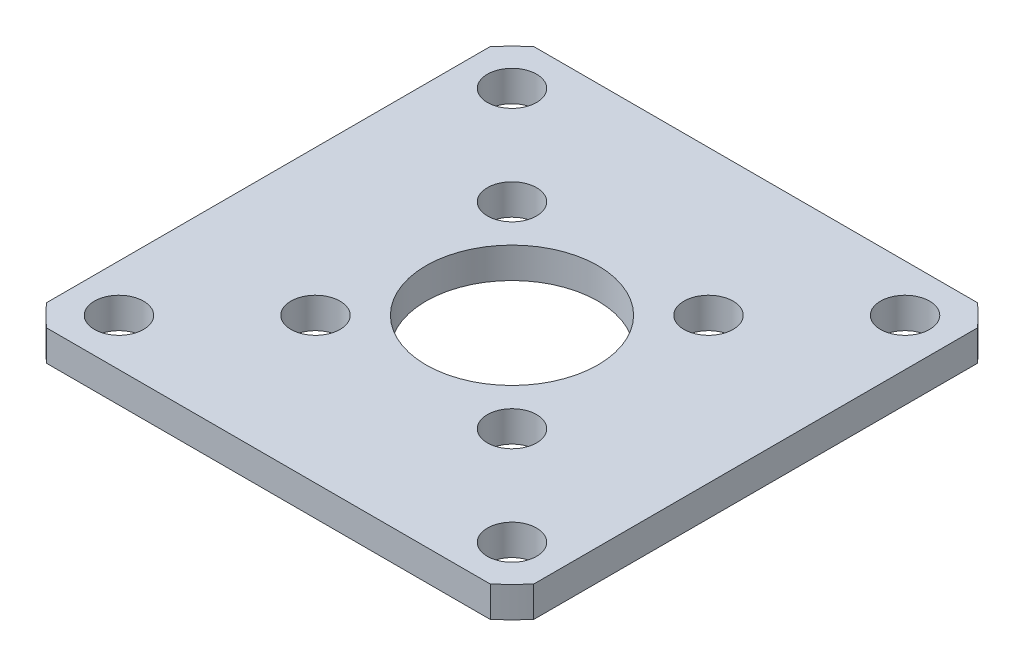
from build123d import *

# Parameters (mm, degrees)
SKETCH1_R           = 26.83
SKETCH1_R_2         = 7
SKETCH1_R_3         = 2
BOSS_EXTRUDE1_DEPTH = 2.5
CUT_EXTRUDE1_DEPTH  = 10
CUT_EXTRUDE2_DEPTH  = 10


with BuildPart() as part:
    # Sketch1 → Boss-Extrude1 (new body)
    with BuildSketch(Plane(origin=(0, 0, 0), x_dir=(1, 0, 0), z_dir=(0, 1, 0))):
        Circle(SKETCH1_R)
        Circle(SKETCH1_R_2, mode=Mode.SUBTRACT)
        with Locations((-16.000000001, 16.000000001)):
            Circle(SKETCH1_R_3, mode=Mode.SUBTRACT)
        with Locations((16.000000001, 16.000000001)):
            Circle(SKETCH1_R_3, mode=Mode.SUBTRACT)
        with Locations((16.000000001, -16.000000001)):
            Circle(SKETCH1_R_3, mode=Mode.SUBTRACT)
        with Locations((-16.000000001, -16.000000001)):
            Circle(SKETCH1_R_3, mode=Mode.SUBTRACT)
    extrude(amount=BOSS_EXTRUDE1_DEPTH)

    # Sketch2 → Cut-Extrude1 (cut)
    with BuildSketch(Plane(origin=(0, 2.5, 0), x_dir=(1, 0, 0), z_dir=(0, 1, 0))):
        with BuildLine():
            ThreePointArc((-6.000000001, 8.000000001), (-9.414213563, 9.414213563), (-8.000000001, 6.000000001))
            Line((-8.000000001, 6.000000001), (-8.000000001, 8.000000001))
            Line((-8.000000001, 8.000000001), (-6.000000001, 8.000000001))
        make_face()
        with BuildLine():
            Line((-8.000000001, 8.000000001), (-8.000000001, 6.000000001))
            ThreePointArc((-8.000000001, 6.000000001), (-6.585786438, 6.585786438), (-6.000000001, 8.000000001))
            Line((-6.000000001, 8.000000001), (-8.000000001, 8.000000001))
        make_face()
        with BuildLine():
            ThreePointArc((6.000000001, 8.000000001), (6.585786438, 6.585786438), (8.000000001, 6.000000001))
            Line((8.000000001, 6.000000001), (8.000000001, 8.000000001))
            Line((8.000000001, 8.000000001), (6.000000001, 8.000000001))
        make_face()
        with BuildLine():
            Line((8.000000001, 8.000000001), (8.000000001, 6.000000001))
            ThreePointArc((8.000000001, 6.000000001), (9.414213563, 6.585786438), (10.000000001, 8.000000001))
            ThreePointArc((10.000000001, 8.000000001), (8.000000001, 10.000000001), (6.000000001, 8.000000001))
            Line((6.000000001, 8.000000001), (8.000000001, 8.000000001))
        make_face()
        with BuildLine():
            Line((-6.000000001, -8.000000001), (-8.000000001, -8.000000001))
            Line((-8.000000001, -8.000000001), (-8.000000001, -6.000000001))
            ThreePointArc((-8.000000001, -6.000000001), (-9.414213563, -9.414213563), (-6.000000001, -8.000000001))
        make_face()
        with BuildLine():
            ThreePointArc((-6.000000001, -8.000000001), (-6.152240936, -7.234633136), (-6.585786438, -6.585786438))
            Line((-6.585786438, -6.585786438), (-8.000000001, -8.000000001))
            Line((-8.000000001, -8.000000001), (-6.000000001, -8.000000001))
        make_face()
        with BuildLine():
            Line((-8.000000001, -8.000000001), (-6.585786438, -6.585786438))
            ThreePointArc((-6.585786438, -6.585786438), (-7.234633136, -6.152240936), (-8.000000001, -6.000000001))
            Line((-8.000000001, -6.000000001), (-8.000000001, -8.000000001))
        make_face()
        with BuildLine():
            ThreePointArc((8.000000001, -6.000000001), (6.585786438, -6.585786438), (6.000000001, -8.000000001))
            Line((6.000000001, -8.000000001), (8.000000001, -8.000000001))
            Line((8.000000001, -8.000000001), (8.000000001, -6.000000001))
        make_face()
        with BuildLine():
            Line((8.000000001, -8.000000001), (6.000000001, -8.000000001))
            ThreePointArc((6.000000001, -8.000000001), (8.000000001, -10.000000001), (10.000000001, -8.000000001))
            ThreePointArc((10.000000001, -8.000000001), (9.414213563, -6.585786438), (8.000000001, -6.000000001))
            Line((8.000000001, -6.000000001), (8.000000001, -8.000000001))
        make_face()
    extrude(amount=-CUT_EXTRUDE1_DEPTH, mode=Mode.SUBTRACT)

    # Sketch3 → Cut-Extrude2 (cut)
    with BuildSketch(Plane(origin=(0, 2.5, 0), x_dir=(1, 0, 0), z_dir=(0, 1, 0))):
        with BuildLine():
            Line((-19.833935995, -18.068311569), (-19.833935995, 18.068311569))
            ThreePointArc((-19.833935995, 18.068311569), (-26.83, 0), (-19.833935995, -18.068311569))
        make_face()
        with BuildLine():
            Line((-18.068311569, 19.833935995), (18.068311569, 19.833935995))
            ThreePointArc((18.068311569, 19.833935995), (0, 26.83), (-18.068311569, 19.833935995))
        make_face()
        with BuildLine():
            ThreePointArc((26.83, 0), (25.019926086, 9.687734443), (19.833935995, 18.068311569))
            Line((19.833935995, 18.068311569), (19.833935995, -18.068311569))
            ThreePointArc((19.833935995, -18.068311569), (25.019926086, -9.687734443), (26.83, 0))
        make_face()
        with BuildLine():
            ThreePointArc((-18.068311569, -19.833935995), (0, -26.83), (18.068311569, -19.833935995))
            Line((18.068311569, -19.833935995), (-18.068311569, -19.833935995))
        make_face()
    extrude(amount=-CUT_EXTRUDE2_DEPTH, mode=Mode.SUBTRACT)


solid = part.part
